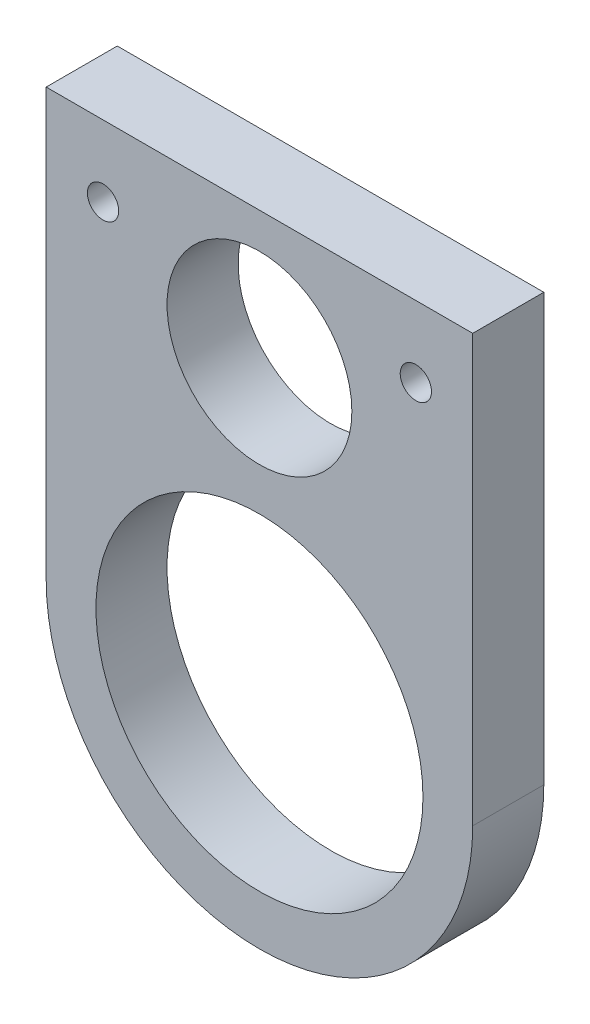
from build123d import *

# Parameters (mm, degrees)
BOSS_EXTRUDE1_DEPTH = 6.35
SKETCH2_R           = 14.605
CUT_EXTRUDE3_DEPTH  = 6.35
SKETCH3_R           = 8.255
CUT_EXTRUDE4_DEPTH  = 6.35
SKETCH5_R           = 1.397
CUT_EXTRUDE5_DEPTH  = 6.35


with BuildPart() as part:
    # Sketch1 → Boss-Extrude1 (new body)
    with BuildSketch(Plane.XY):
        with BuildLine():
            Line((0, 0), (38.1, 0))
            Line((38.1, 0), (38.1, -38.1))
            ThreePointArc((38.1, -38.1), (19.05, -57.15), (0, -38.1))
            Line((0, -38.1), (0, 0))
        make_face()
    extrude(amount=BOSS_EXTRUDE1_DEPTH)

    # Sketch2 → Cut-Extrude3 (cut)
    with BuildSketch(Plane.XY.offset(6.35)):
        with Locations((19.05, -38.1)):
            Circle(SKETCH2_R)
    extrude(amount=-CUT_EXTRUDE3_DEPTH, mode=Mode.SUBTRACT)

    # Sketch3 → Cut-Extrude4 (cut)
    with BuildSketch(Plane.XY.offset(6.35)):
        with Locations((19.05, -11.43)):
            Circle(SKETCH3_R)
    extrude(amount=-CUT_EXTRUDE4_DEPTH, mode=Mode.SUBTRACT)

    # Sketch5 → Cut-Extrude5 (cut)
    with BuildSketch(Plane.XY.offset(6.35)):
        with Locations((5.08, -6.35)):
            Circle(SKETCH5_R)
        with Locations((33.02, -6.35)):
            Circle(SKETCH5_R)
    extrude(amount=-CUT_EXTRUDE5_DEPTH, mode=Mode.SUBTRACT)


solid = part.part
